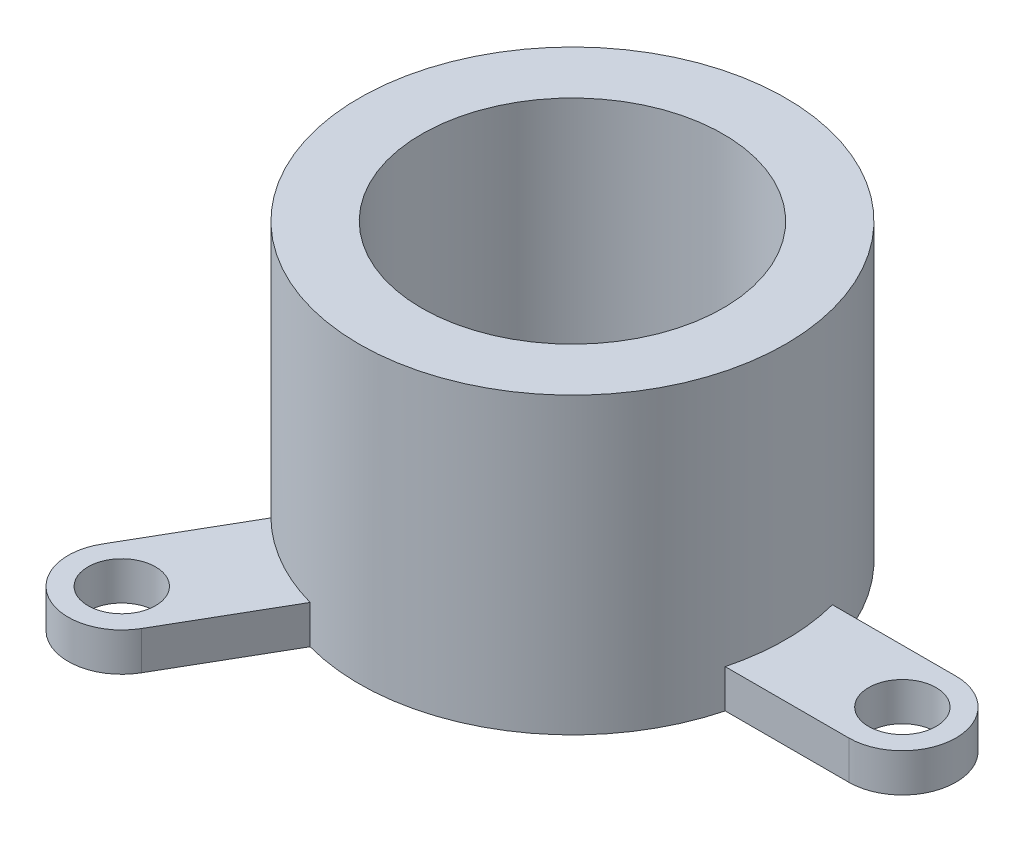
from build123d import *

# Parameters (mm, degrees)
SKETCH1_R           = 50
SKETCH1_R_2         = 35.355339059
BOSS_EXTRUDE1_DEPTH = 69
SKETCH2_R           = 7.911207782
BOSS_EXTRUDE2_DEPTH = 9
CIRPATTERN1_COUNT   = 3


with BuildPart() as part:
    # Sketch1 → Boss-Extrude1 (new body)
    with BuildSketch(Plane(origin=(0, 0, 0), x_dir=(1, 0, 0), z_dir=(0, 1, 0))):
        Circle(SKETCH1_R)
        Circle(SKETCH1_R_2, mode=Mode.SUBTRACT)
    extrude(amount=BOSS_EXTRUDE1_DEPTH)

    # Sketch2 → Boss-Extrude2 (add)
    with BuildSketch(Plane.XZ):
        with BuildLine():
            Line((77.363229747, 12.564610951), (48.395563347, 12.564610951))
            ThreePointArc((48.395563347, 12.564610951), (50, 0), (48.395563347, -12.564610951))
            Line((48.395563347, -12.564610951), (77.363229747, -12.564610951))
            ThreePointArc((77.363229747, -12.564610951), (89.927840698, 0), (77.363229747, 12.564610951))
        make_face()
        with Locations((77.363229747, 0)):
            Circle(SKETCH2_R, mode=Mode.SUBTRACT)
    boss_extrude2 = extrude(amount=-BOSS_EXTRUDE2_DEPTH)

    # CirPattern1: Boss-Extrude2 ×3 about axis
    cirpattern1_axis = Axis((0, -3.45, 0), (0, 1, 0))
    for i in range(1, CIRPATTERN1_COUNT):
        add(boss_extrude2.rotate(cirpattern1_axis, i * 360 / CIRPATTERN1_COUNT))


solid = part.part
